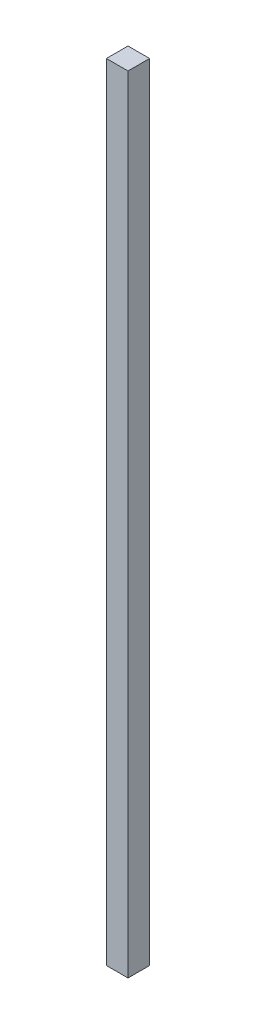
from build123d import *

# Parameters (mm, degrees)
SKETCH_34_W         = 44.1
SKETCH_34_H         = 35
EXTRUDE_1_DEPTH     = 20.9
SKETCH_35_W         = 8
SKETCH_35_H         = 8
EXTRUDE_2_DEPTH     = 109.1
SKETCH_36_W         = 3
SKETCH_36_H         = 3
EXTRUDE_3_DEPTH     = 109
SKETCH_38_W         = 130
SKETCH_38_H         = 130
CUT_EXTRUDE_2_DEPTH = 131


with BuildPart() as part:
    # ｽｹｯﾁ34 → ﾎﾞｽ - 押し出し1 (new body)
    with BuildSketch(Plane(origin=(0, 0, 0), x_dir=(1, 0, 0), z_dir=(0, 1, 0))):
        Rectangle(SKETCH_34_W, SKETCH_34_H)
    extrude(amount=EXTRUDE_1_DEPTH)

    # ｽｹｯﾁ35 → ﾎﾞｽ - 押し出し2 (add)
    with BuildSketch(Plane(origin=(0, 20.9, 0), x_dir=(1, 0, 0), z_dir=(0, 1, 0))):
        Rectangle(SKETCH_35_W, SKETCH_35_H)
    extrude(amount=EXTRUDE_2_DEPTH)

    # ｽｹｯﾁ36 → ﾎﾞｽ - 押し出し3 (add)
    with BuildSketch(Plane(origin=(0, 130, 0), x_dir=(1, 0, 0), z_dir=(0, 1, 0))):
        Rectangle(SKETCH_36_W, SKETCH_36_H)
    extrude(amount=EXTRUDE_3_DEPTH)

    # ｽｹｯﾁ38 → ｶｯﾄ - 押し出し2 (cut, through all)
    with BuildSketch(Plane(origin=(0, 130, 0), x_dir=(1, 0, 0), z_dir=(0, 1, 0))):
        Rectangle(SKETCH_38_W, SKETCH_38_H)
    extrude(amount=-CUT_EXTRUDE_2_DEPTH, mode=Mode.SUBTRACT)


solid = part.part
